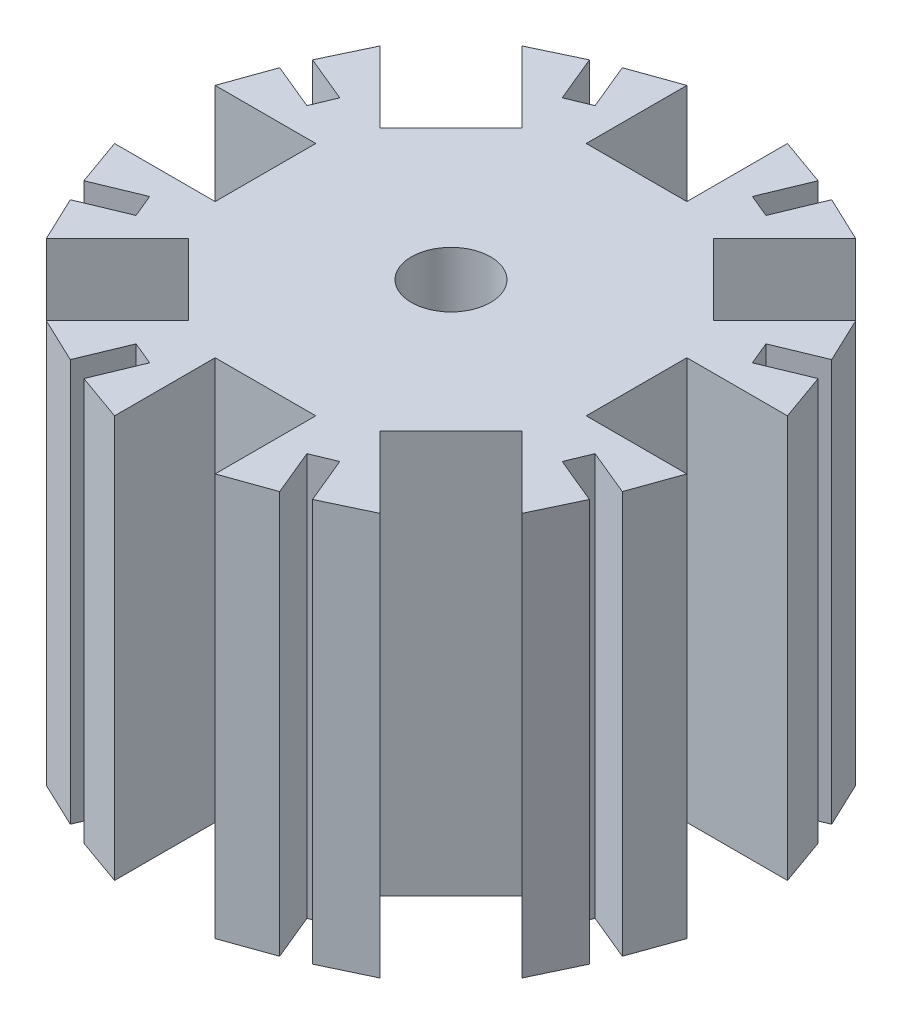
from build123d import *

# Parameters (mm, degrees)
BOSS_EXTRUDE3_DEPTH = 50.8
CIRPATTERN2_COUNT   = 8


with BuildPart() as part:
    # Sketch1 → Boss-Extrude3 (new body)
    with BuildSketch(Plane(origin=(0, 0, 0), x_dir=(1, 0, 0), z_dir=(0, 1, 0))):
        with BuildLine():
            Line((21.052414425, 12.072158304), (12.072158304, 21.052414425))
            Line((12.072158304, 21.052414425), (2.487247326, 4.337464782))
            ThreePointArc((2.487247326, 4.337464782), (3.957792808, 3.055466591), (4.825800212, 1.30830131))
            Line((4.825800212, 1.30830131), (23.42261, 6.35))
            Line((23.42261, 6.35), (36.12261, 6.35))
            Line((36.12261, 6.35), (33.980449989, 12.356865623))
            Line((33.980449989, 12.356865623), (28.113814957, 9.926825827))
            Line((28.113814957, 9.926825827), (26.89879506, 12.860143343))
            Line((26.89879506, 12.860143343), (32.765430091, 15.290183139))
            Line((32.765430091, 15.290183139), (30.032670546, 21.052414425))
            Line((30.032670546, 21.052414425), (21.052414425, 12.072158304))
        make_face()
    extrude(amount=BOSS_EXTRUDE3_DEPTH)


with BuildPart() as cirpattern2_1:
    # CirPattern2: pattern copy
    add(part.part.rotate(Axis((0, -0.25, 0), (0, 1, 0)), 1 * 360 / CIRPATTERN2_COUNT))


with BuildPart() as cirpattern2_2:
    # CirPattern2: pattern copy
    add(part.part.rotate(Axis((0, -0.25, 0), (0, 1, 0)), 2 * 360 / CIRPATTERN2_COUNT))


with BuildPart() as cirpattern2_3:
    # CirPattern2: pattern copy
    add(part.part.rotate(Axis((0, -0.25, 0), (0, 1, 0)), 3 * 360 / CIRPATTERN2_COUNT))


with BuildPart() as cirpattern2_4:
    # CirPattern2: pattern copy
    add(part.part.rotate(Axis((0, -0.25, 0), (0, 1, 0)), 4 * 360 / CIRPATTERN2_COUNT))


with BuildPart() as cirpattern2_5:
    # CirPattern2: pattern copy
    add(part.part.rotate(Axis((0, -0.25, 0), (0, 1, 0)), 5 * 360 / CIRPATTERN2_COUNT))


with BuildPart() as cirpattern2_6:
    # CirPattern2: pattern copy
    add(part.part.rotate(Axis((0, -0.25, 0), (0, 1, 0)), 6 * 360 / CIRPATTERN2_COUNT))


with BuildPart() as cirpattern2_7:
    # CirPattern2: pattern copy
    add(part.part.rotate(Axis((0, -0.25, 0), (0, 1, 0)), 7 * 360 / CIRPATTERN2_COUNT))


with BuildPart() as cirpattern2_1_1:
    add(cirpattern2_1.part)

    # Combine2: union CirPattern2_2, CirPattern2_3, CirPattern2_4, CirPattern2_5, CirPattern2_6, CirPattern2_7, part
    add(cirpattern2_2.part)
    add(cirpattern2_3.part)
    add(cirpattern2_4.part)
    add(cirpattern2_5.part)
    add(cirpattern2_6.part)
    add(cirpattern2_7.part)
    add(part.part)


solid = cirpattern2_1_1.part
